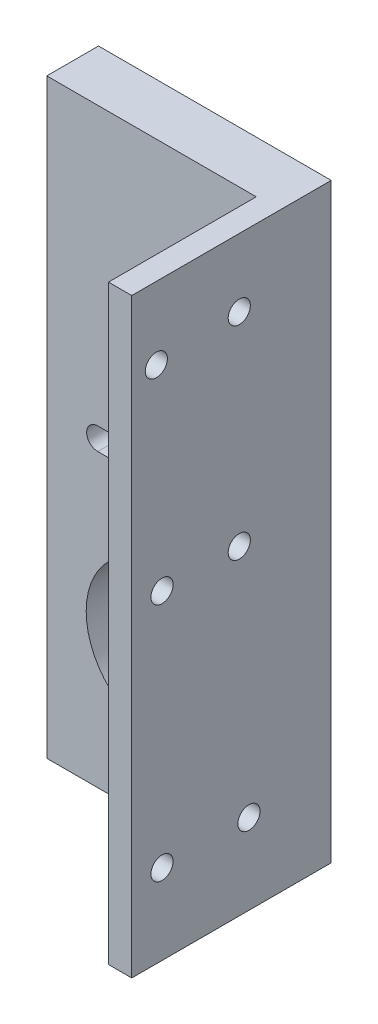
from build123d import *

# Parameters (mm, degrees)
SKETCH_1_W      = 31.500863908
SKETCH_1_H      = 80
SKETCH_1_R      = 10.417524335
SKETCH_1_R_2    = 1.56
EXTRUDE_1_DEPTH = 7
SKETCH_5_W      = 3.14774975
SKETCH_5_H      = 80
EXTRUDE_2_DEPTH = 27
MM_1_D          = 3
MM_1_DEPTH      = 3.14774975


with BuildPart() as part:
    # 草图1 → 凸台-拉伸1 (new body)
    with BuildSketch(Plane.XY):
        with Locations((0, 13.377078694)):
            Rectangle(SKETCH_1_W, SKETCH_1_H)
        with Locations((0, -6.708333333)):
            Circle(SKETCH_1_R, mode=Mode.SUBTRACT)
        with Locations((0, -20.208333333)):
            Circle(SKETCH_1_R_2, mode=Mode.SUBTRACT)
        with BuildLine():
            Line((8.85, 15.791666667), (-8.85, 15.791666667))
            ThreePointArc((-8.85, 15.791666667), (-10.35, 14.291666667), (-8.85, 12.791666667))
            Line((-8.85, 12.791666667), (8.85, 12.791666667))
            ThreePointArc((8.85, 12.791666667), (10.35, 14.291666667), (8.85, 15.791666667))
        make_face(mode=Mode.SUBTRACT)
    extrude(amount=EXTRUDE_1_DEPTH)

    # 草图5 → 凸台-拉伸2 (add)
    with BuildSketch(Plane.XY):
        with Locations((14.176557079, 13.377078694)):
            Rectangle(SKETCH_5_W, SKETCH_5_H)
    extrude(amount=EXTRUDE_2_DEPTH)

    # 大小mm 暗销孔1
    with Locations(Plane.ZY.offset(-12.602682204)):
        with Locations((12.444794173, 44.192540423), (23.673777791, 43.57849825), (11.130072788, -15.739218974), (22.900107862, -15.739218974), (12.444794173, 16.704513785), (22.900107862, 16.704513785)):
            Hole(MM_1_D / 2, depth=MM_1_DEPTH)


solid = part.part
